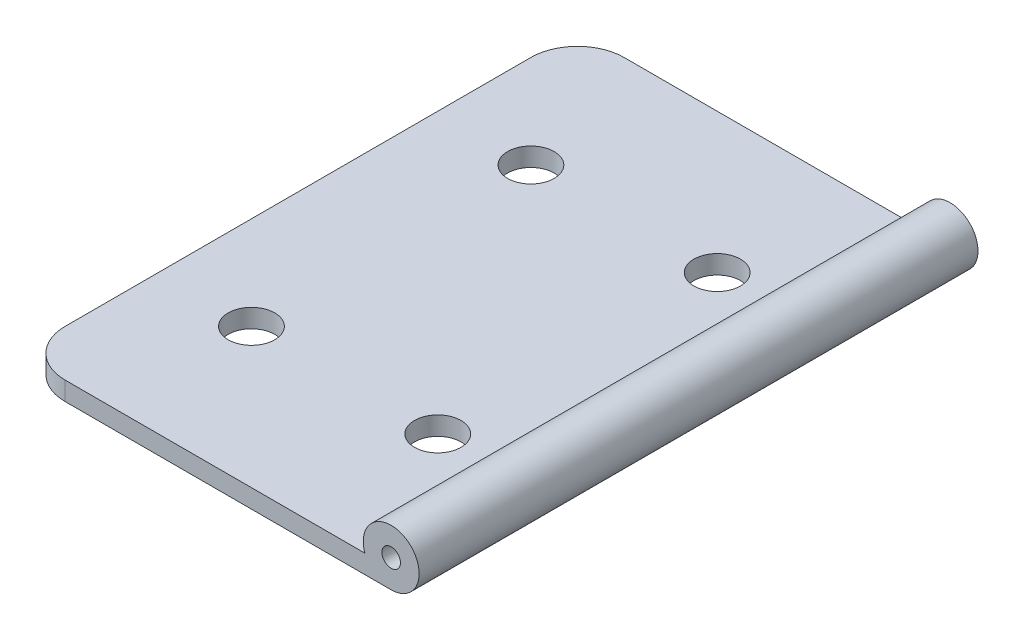
from build123d import *

# Parameters (mm, degrees)
SKETCH1_W           = 40
SKETCH1_H           = 60
SKETCH1_R           = 2.5
BOSS_EXTRUDE1_DEPTH = 2
FILLET1_R           = 5
SKETCH2_R           = 3
SKETCH2_R_2         = 1
BOSS_EXTRUDE2_DEPTH = 60


with BuildPart() as part:
    # Sketch1 → Boss-Extrude1 (new body)
    with BuildSketch(Plane(origin=(0, 0, 0), x_dir=(1, 0, 0), z_dir=(0, 1, 0))):
        with Locations((-20, 0)):
            Rectangle(SKETCH1_W, SKETCH1_H)
        with Locations((-30, 15)):
            Circle(SKETCH1_R, mode=Mode.SUBTRACT)
        with Locations((-10, 15)):
            Circle(SKETCH1_R, mode=Mode.SUBTRACT)
        with Locations((-10, -15)):
            Circle(SKETCH1_R, mode=Mode.SUBTRACT)
        with Locations((-30, -15)):
            Circle(SKETCH1_R, mode=Mode.SUBTRACT)
    extrude(amount=BOSS_EXTRUDE1_DEPTH)

    # Fillet1
    fillet1_edges = [part.edges().sort_by_distance(p)[0] for p in [
        (-40, 1, 30),
        (-40, 1, -30),
    ]]
    fillet(fillet1_edges, radius=FILLET1_R)

    # Sketch2 → Boss-Extrude2 (add)
    with BuildSketch(Plane.XY.offset(30)):
        with Locations((0, 3)):
            Circle(SKETCH2_R)
        with Locations((0, 3)):
            Circle(SKETCH2_R_2, mode=Mode.SUBTRACT)
    extrude(amount=-BOSS_EXTRUDE2_DEPTH)


solid = part.part
